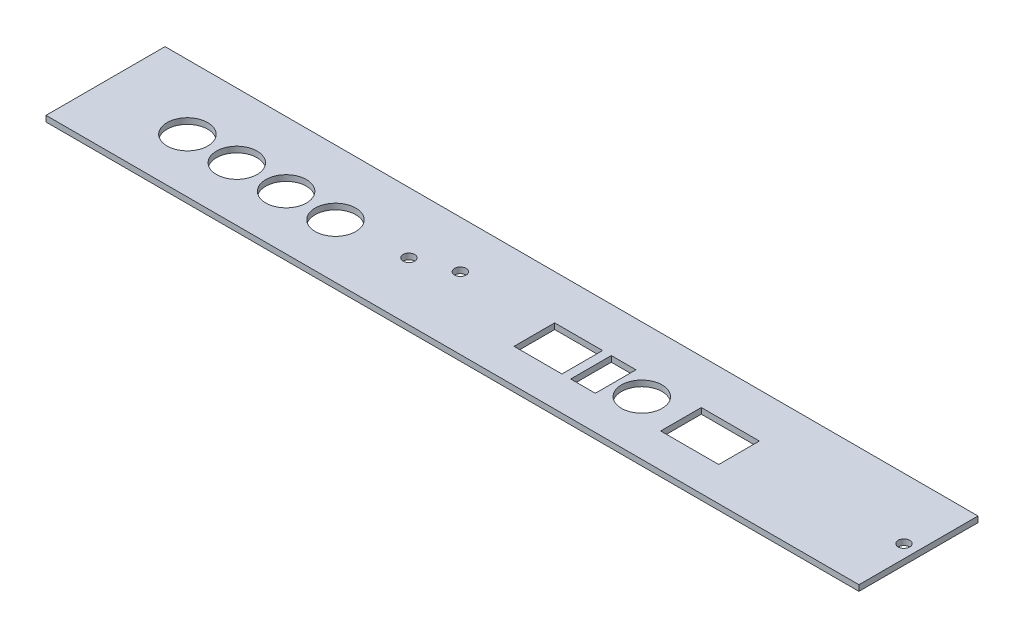
from build123d import *

# Parameters (mm, degrees)
SKETCH_1_W      = 280
SKETCH_1_H      = 41
SKETCH_1_R      = 7
SKETCH_1_R_2    = 2
SKETCH_1_W_2    = 16.5
SKETCH_1_H_2    = 14
SKETCH_1_W_3    = 8.5
SKETCH_1_W_4    = 20
EXTRUDE_1_DEPTH = 2


with BuildPart() as part:
    # 草图1 → 凸台-拉伸1 (new body)
    with BuildSketch(Plane(origin=(0, 0, 0), x_dir=(1, 0, 0), z_dir=(0, 1, 0))):
        with Locations((140, 20.5)):
            Rectangle(SKETCH_1_W, SKETCH_1_H)
        with Locations((30, 18.7)):
            Circle(SKETCH_1_R, mode=Mode.SUBTRACT)
        with Locations((47, 18.7)):
            Circle(SKETCH_1_R, mode=Mode.SUBTRACT)
        with Locations((64, 18.7)):
            Circle(SKETCH_1_R, mode=Mode.SUBTRACT)
        with Locations((81, 18.7)):
            Circle(SKETCH_1_R, mode=Mode.SUBTRACT)
        with Locations((186.5, 18.7)):
            Circle(SKETCH_1_R, mode=Mode.SUBTRACT)
        with Locations((118, 24.7)):
            Circle(SKETCH_1_R_2, mode=Mode.SUBTRACT)
        with Locations((105, 20)):
            Circle(SKETCH_1_R_2, mode=Mode.SUBTRACT)
        with Locations((275.5, 20)):
            Circle(SKETCH_1_R_2, mode=Mode.SUBTRACT)
        with Locations((157.75, 18.7)):
            Rectangle(SKETCH_1_W_2, SKETCH_1_H_2, mode=Mode.SUBTRACT)
        with Locations((173.25, 18.7)):
            Rectangle(SKETCH_1_W_3, SKETCH_1_H_2, mode=Mode.SUBTRACT)
        with Locations((210, 18.7)):
            Rectangle(SKETCH_1_W_4, SKETCH_1_H_2, mode=Mode.SUBTRACT)
    extrude(amount=EXTRUDE_1_DEPTH)


solid = part.part
